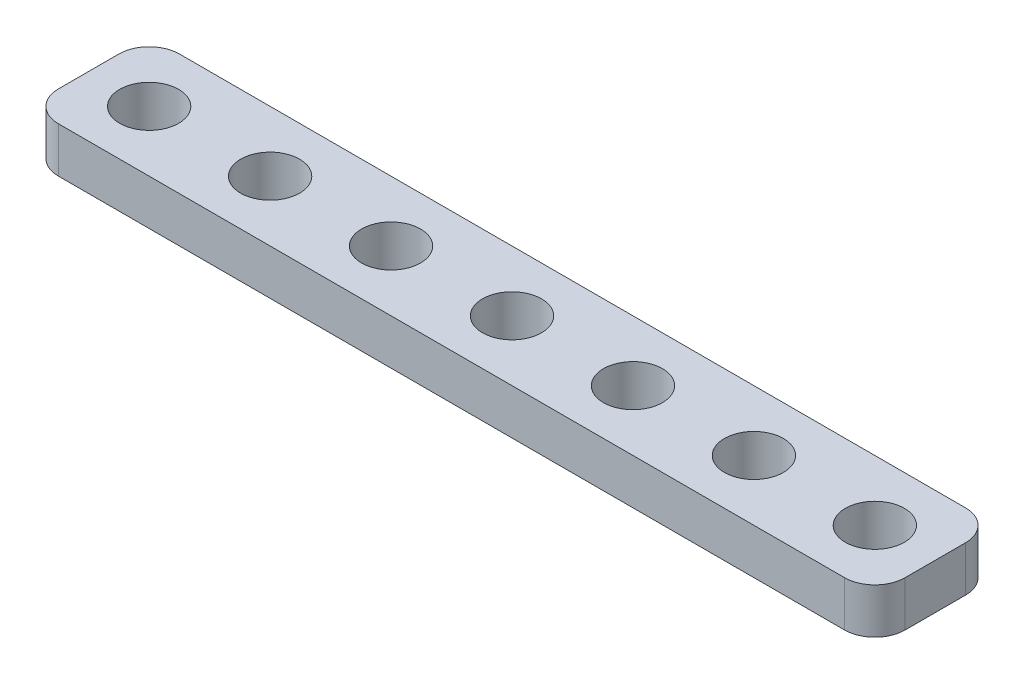
from build123d import *

# Parameters (mm, degrees)
BOSS_EXTRUDE1_DEPTH = 3
SKETCH2_R           = 1.95
CUT_EXTRUDE1_DEPTH  = 4


with BuildPart() as part:
    # Sketch1 → Boss-Extrude1 (new body)
    with BuildSketch(Plane(origin=(0, 0, 0), x_dir=(1, 0, 0), z_dir=(0, 1, 0))):
        with BuildLine():
            Line((2, 0), (54, 0))
            ThreePointArc((54, 0), (55.414213562, -0.585786438), (56, -2))
            Line((56, -2), (56, -6))
            ThreePointArc((56, -6), (55.414213562, -7.414213562), (54, -8))
            Line((54, -8), (2, -8))
            ThreePointArc((2, -8), (0.585786438, -7.414213562), (0, -6))
            Line((0, -6), (0, -2))
            ThreePointArc((0, -2), (0.585786438, -0.585786438), (2, 0))
        make_face()
    extrude(amount=BOSS_EXTRUDE1_DEPTH)

    # Sketch2 → Cut-Extrude1 (cut, through all)
    with BuildSketch(Plane(origin=(0, 3, 0), x_dir=(1, 0, 0), z_dir=(0, 1, 0))):
        with Locations((52, -4)):
            Circle(SKETCH2_R)
        with Locations((44, -4)):
            Circle(SKETCH2_R)
        with Locations((-12, -4)):
            Circle(SKETCH2_R)
        with Locations((-4, -4)):
            Circle(SKETCH2_R)
        with Locations((4, -4)):
            Circle(SKETCH2_R)
        with Locations((12, -4)):
            Circle(SKETCH2_R)
        with Locations((20, -4)):
            Circle(SKETCH2_R)
        with Locations((28, -4)):
            Circle(SKETCH2_R)
        with Locations((36, -4)):
            Circle(SKETCH2_R)
    extrude(amount=-CUT_EXTRUDE1_DEPTH, mode=Mode.SUBTRACT)


solid = part.part
